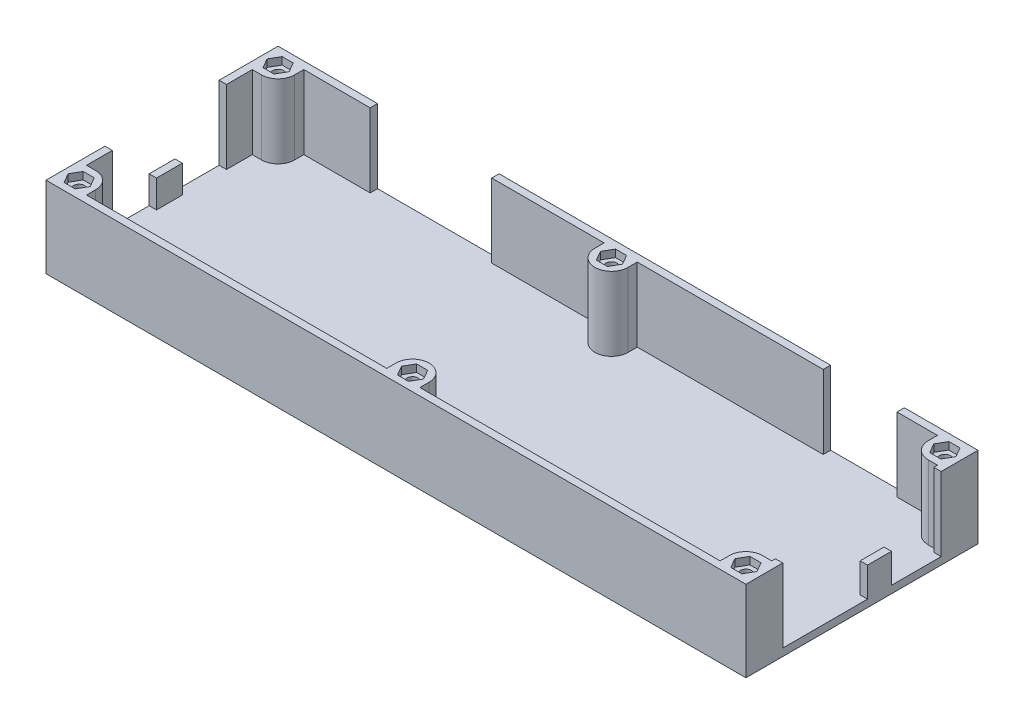
from build123d import *

# Parameters (mm, degrees)
BOSS_EXTRUDE1_DEPTH     = 2
SKETCH1_4_R             = 1.5
BOSS_EXTRUDE2_DEPTH     = 19
BOSS_EXTRUDE2_2_DEPTH   = 19
BOSS_EXTRUDE2_3_DEPTH   = 19
BOSS_EXTRUDE2_4_DEPTH   = 19
BOSS_EXTRUDE2_5_DEPTH   = 19
BOSS_EXTRUDE2_6_DEPTH   = 19
SKETCH1_5_R             = 1.5
BOSS_EXTRUDE3_DEPTH     = 20
BOSS_EXTRUDE4_DEPTH     = 22
SKETCH2_W               = 23
SKETCH2_H               = 8
SKETCH2_W_2             = 13.5
SKETCH2_H_2             = 13.3
CUT_EXTRUDE1_DEPTH      = 3
SKETCH3_W               = 20
SKETCH3_H               = 12
SKETCH3_W_2             = 33
CUT_EXTRUDE2_DEPTH      = 3
SKETCH4_W               = 12
SKETCH4_H               = 7.5
CUT_EXTRUDE3_DEPTH      = 3
CUT_EXTRUDE4_DEPTH      = 194.845943986
CUT_EXTRUDE4_DEPTH_BACK = 2
SKETCH6_W               = 20
SKETCH6_H               = 8
SKETCH6_W_2             = 33
CUT_EXTRUDE5_DEPTH      = 2
CUT_EXTRUDE6_DEPTH      = 194.845943986
CUT_EXTRUDE6_DEPTH_BACK = 2


with BuildPart() as part:
    # Sketch1 → Boss-Extrude1 (new body)
    with BuildSketch(Plane(origin=(0, 0, 0), x_dir=(1, 0, 0), z_dir=(0, 1, 0))):
        with BuildLine():
            Line((-90.5, 22.5), (-93, 22.5))
            Line((-93, 22.5), (-93, -22.5))
            Line((-93, -22.5), (-90.5, -22.5))
            ThreePointArc((-90.5, -22.5), (-87.318019485, -23.818019485), (-86, -27))
            Line((-86, -27), (-86, -29.5))
            Line((-86, -29.5), (-4.5, -29.5))
            Line((-4.5, -29.5), (-4.5, -27))
            ThreePointArc((-4.5, -27), (0, -22.5), (4.5, -27))
            Line((4.5, -27), (4.5, -29.5))
            Line((4.5, -29.5), (86, -29.5))
            Line((86, -29.5), (86, -27))
            ThreePointArc((86, -27), (87.318019485, -23.818019485), (90.5, -22.5))
            Line((90.5, -22.5), (93, -22.5))
            Line((93, -22.5), (93, 22.5))
            Line((93, 22.5), (90.5, 22.5))
            ThreePointArc((90.5, 22.5), (87.318019485, 23.818019485), (86, 27))
            Line((86, 27), (86, 29.5))
            Line((86, 29.5), (4.5, 29.5))
            Line((4.5, 29.5), (4.5, 27))
            ThreePointArc((4.5, 27), (0, 22.5), (-4.5, 27))
            Line((-4.5, 27), (-4.5, 29.5))
            Line((-4.5, 29.5), (-86, 29.5))
            Line((-86, 29.5), (-86, 27))
            ThreePointArc((-86, 27), (-87.318019485, 23.818019485), (-90.5, 22.5))
        make_face()
    extrude(amount=BOSS_EXTRUDE1_DEPTH)



with BuildPart() as body_2:
    # Sketch1_4 → Boss-Extrude2 (new body)
    with BuildSketch(Plane(origin=(0, 0, 0), x_dir=(1, 0, 0), z_dir=(0, 1, 0))):
        with Locations((-90.5, 27)):
            Circle(SKETCH1_4_R)
    extrude(amount=BOSS_EXTRUDE2_DEPTH)



with BuildPart() as body_3:
    # Sketch1_4 → Boss-Extrude2 2 (new body)
    with BuildSketch(Plane(origin=(0, 0, 0), x_dir=(1, 0, 0), z_dir=(0, 1, 0))):
        with Locations((90.5, 27)):
            Circle(SKETCH1_4_R)
    extrude(amount=BOSS_EXTRUDE2_2_DEPTH)


with BuildPart() as body_4:
    # Sketch1_4 → Boss-Extrude2 3 (new body)
    with BuildSketch(Plane(origin=(0, 0, 0), x_dir=(1, 0, 0), z_dir=(0, 1, 0))):
        with Locations((90.5, -27)):
            Circle(SKETCH1_4_R)
    extrude(amount=BOSS_EXTRUDE2_3_DEPTH)


with BuildPart() as body_5:
    # Sketch1_4 → Boss-Extrude2 4 (new body)
    with BuildSketch(Plane(origin=(0, 0, 0), x_dir=(1, 0, 0), z_dir=(0, 1, 0))):
        with Locations((-90.5, -27)):
            Circle(SKETCH1_4_R)
    extrude(amount=BOSS_EXTRUDE2_4_DEPTH)


with BuildPart() as body_6:
    # Sketch1_4 → Boss-Extrude2 5 (new body)
    with BuildSketch(Plane(origin=(0, 0, 0), x_dir=(1, 0, 0), z_dir=(0, 1, 0))):
        with Locations((0, 27)):
            Circle(SKETCH1_4_R)
    extrude(amount=BOSS_EXTRUDE2_5_DEPTH)


with BuildPart() as body_7:
    # Sketch1_4 → Boss-Extrude2 6 (new body)
    with BuildSketch(Plane(origin=(0, 0, 0), x_dir=(1, 0, 0), z_dir=(0, 1, 0))):
        with Locations((0, -27)):
            Circle(SKETCH1_4_R)
    extrude(amount=BOSS_EXTRUDE2_6_DEPTH)


with BuildPart() as body_2_1:
    add(body_2.part)

    add(body_3.part)  # Boss-Extrude3 merges body 3

    add(body_4.part)  # Boss-Extrude3 merges body 4

    add(body_5.part)  # Boss-Extrude3 merges body 5

    add(body_6.part)  # Boss-Extrude3 merges body 6

    add(body_7.part)  # Boss-Extrude3 merges body 7
    # Sketch1_5 → Boss-Extrude3 (add)
    # profile 1 of 6: a face of its own
    with BuildSketch(Plane(origin=(0, 0, 0), x_dir=(1, 0, 0), z_dir=(0, 1, 0))):
        Polygon((93.5, 27), (92, 29.598076211), (89, 29.598076211), (87.5, 27), (89, 24.401923789), (92, 24.401923789), align=None)
        with Locations((90.5, 27)):
            Circle(SKETCH1_5_R, mode=Mode.SUBTRACT)
    # profile 2 of 6: a face of its own
    with BuildSketch(Plane(origin=(0, 0, 0), x_dir=(1, 0, 0), z_dir=(0, 1, 0))):
        Polygon((-92, 29.598076211), (-93.5, 27), (-92, 24.401923789), (-89, 24.401923789), (-87.5, 27), (-89, 29.598076211), align=None)
        with Locations((-90.5, 27)):
            Circle(SKETCH1_5_R, mode=Mode.SUBTRACT)
    # profile 3 of 6: a face of its own
    with BuildSketch(Plane(origin=(0, 0, 0), x_dir=(1, 0, 0), z_dir=(0, 1, 0))):
        Polygon((87.5, -27), (89, -29.598076211), (92, -29.598076211), (93.5, -27), (92, -24.401923789), (89, -24.401923789), align=None)
        with Locations((90.5, -27)):
            Circle(SKETCH1_5_R, mode=Mode.SUBTRACT)
    # profile 4 of 6: a face of its own
    with BuildSketch(Plane(origin=(0, 0, 0), x_dir=(1, 0, 0), z_dir=(0, 1, 0))):
        Polygon((-93.5, -27), (-92, -29.598076211), (-89, -29.598076211), (-87.5, -27), (-89, -24.401923789), (-92, -24.401923789), align=None)
        with Locations((-90.5, -27)):
            Circle(SKETCH1_5_R, mode=Mode.SUBTRACT)
    # profile 5 of 6: a face of its own
    with BuildSketch(Plane(origin=(0, 0, 0), x_dir=(1, 0, 0), z_dir=(0, 1, 0))):
        Polygon((3, -27), (1.5, -24.401923789), (-1.5, -24.401923789), (-3, -27), (-1.5, -29.598076211), (1.5, -29.598076211), align=None)
        with Locations((0, -27)):
            Circle(SKETCH1_5_R, mode=Mode.SUBTRACT)
    # profile 6 of 6: a face of its own
    with BuildSketch(Plane(origin=(0, 0, 0), x_dir=(1, 0, 0), z_dir=(0, 1, 0))):
        Polygon((1.5, 24.401923789), (3, 27), (1.5, 29.598076211), (-1.5, 29.598076211), (-3, 27), (-1.5, 24.401923789), align=None)
        with Locations((0, 27)):
            Circle(SKETCH1_5_R, mode=Mode.SUBTRACT)
    extrude(amount=BOSS_EXTRUDE3_DEPTH)


with BuildPart() as part_1:
    add(part.part)

    add(body_2_1.part)  # Boss-Extrude4 merges body 2
    # Sketch1_6 → Boss-Extrude4 (add)
    with BuildSketch(Plane(origin=(0, 0, 0), x_dir=(1, 0, 0), z_dir=(0, 1, 0))):
        Polygon((-95, -22.5), (-95, -31.5), (-86, -31.5), (86, -31.5), (95, -31.5), (95, -22.5), (95, 22.5), (95, 31.5), (86, 31.5), (4.5, 31.5), (-4.5, 31.5), (-86, 31.5), (-95, 31.5), (-95, 22.5), align=None)
        Polygon((-89, -29.598076211), (-92, -29.598076211), (-93.5, -27), (-92, -24.401923789), (-89, -24.401923789), (-87.5, -27), align=None, mode=Mode.SUBTRACT)
        Polygon((-1.5, -24.401923789), (1.5, -24.401923789), (3, -27), (1.5, -29.598076211), (-1.5, -29.598076211), (-3, -27), align=None, mode=Mode.SUBTRACT)
        Polygon((92, -29.598076211), (89, -29.598076211), (87.5, -27), (89, -24.401923789), (92, -24.401923789), (93.5, -27), align=None, mode=Mode.SUBTRACT)
        Polygon((-92, 24.401923789), (-93.5, 27), (-92, 29.598076211), (-89, 29.598076211), (-87.5, 27), (-89, 24.401923789), align=None, mode=Mode.SUBTRACT)
        Polygon((1.5, 29.598076211), (3, 27), (1.5, 24.401923789), (-1.5, 24.401923789), (-3, 27), (-1.5, 29.598076211), align=None, mode=Mode.SUBTRACT)
        with BuildLine():
            Line((-93, -22.5), (-93, 22.5))
            Line((-93, 22.5), (-90.5, 22.5))
            ThreePointArc((-90.5, 22.5), (-87.318019485, 23.818019485), (-86, 27))
            Line((-86, 27), (-86, 29.5))
            Line((-86, 29.5), (-4.5, 29.5))
            Line((-4.5, 29.5), (-4.5, 27))
            ThreePointArc((-4.5, 27), (0, 22.5), (4.5, 27))
            Line((4.5, 27), (4.5, 29.5))
            Line((4.5, 29.5), (86, 29.5))
            Line((86, 29.5), (86, 27))
            ThreePointArc((86, 27), (87.318019485, 23.818019485), (90.5, 22.5))
            Line((90.5, 22.5), (93, 22.5))
            Line((93, 22.5), (93, -22.5))
            Line((93, -22.5), (90.5, -22.5))
            ThreePointArc((90.5, -22.5), (87.318019485, -23.818019485), (86, -27))
            Line((86, -27), (86, -29.5))
            Line((86, -29.5), (4.5, -29.5))
            Line((4.5, -29.5), (4.5, -27))
            ThreePointArc((4.5, -27), (0, -22.5), (-4.5, -27))
            Line((-4.5, -27), (-4.5, -29.5))
            Line((-4.5, -29.5), (-86, -29.5))
            Line((-86, -29.5), (-86, -27))
            ThreePointArc((-86, -27), (-87.318019485, -23.818019485), (-90.5, -22.5))
            Line((-90.5, -22.5), (-93, -22.5))
        make_face(mode=Mode.SUBTRACT)
        Polygon((89, 29.598076211), (92, 29.598076211), (93.5, 27), (92, 24.401923789), (89, 24.401923789), (87.5, 27), align=None, mode=Mode.SUBTRACT)
    extrude(amount=BOSS_EXTRUDE4_DEPTH)

    # Sketch2 → Cut-Extrude1 (cut)
    with BuildSketch(Plane(origin=(95, 0, 0), x_dir=(0, 0, -1), z_dir=(1, 0, 0))):
        with Locations((-10, 6)):
            Rectangle(SKETCH2_W, SKETCH2_H)
        with Locations((14.75, 8.65)):
            Rectangle(SKETCH2_W_2, SKETCH2_H_2)
    extrude(amount=-CUT_EXTRUDE1_DEPTH, mode=Mode.SUBTRACT)

    # Sketch3 → Cut-Extrude2 (cut)
    with BuildSketch(Plane(origin=(0, 0, -31.5), x_dir=(-1, 0, 0), z_dir=(0, 0, -1))):
        with Locations((-65, 8)):
            Rectangle(SKETCH3_W, SKETCH3_H)
        with Locations((51.5, 8)):
            Rectangle(SKETCH3_W_2, SKETCH3_H)
    extrude(amount=-CUT_EXTRUDE2_DEPTH, mode=Mode.SUBTRACT)

    # Sketch4 → Cut-Extrude3 (cut)
    with BuildSketch(Plane.ZY.offset(95)):
        with Locations((-9.5, 5.75)):
            Rectangle(SKETCH4_W, SKETCH4_H)
        with Locations((9.5, 5.75)):
            Rectangle(SKETCH4_W, SKETCH4_H)
    extrude(amount=-CUT_EXTRUDE3_DEPTH, mode=Mode.SUBTRACT)

    # Sketch5 → Cut-Extrude4 (cut, two sides: drawn at the far end of the back side and taken through both)
    with BuildSketch(Plane(origin=(95, 0, 0), x_dir=(0, 0, -1), z_dir=(1, 0, 0)).offset(-CUT_EXTRUDE4_DEPTH_BACK)):
        Polygon((21.5, 146.769333883), (21.5, 22), (21.5, 15.3), (8, 15.3), (8, 10), (-21.5, 10), (-21.5, 22), (-21.5, 146.769333883), (-21.5, 396.30800165), (21.5, 396.30800165), align=None)
    extrude(amount=CUT_EXTRUDE4_DEPTH + CUT_EXTRUDE4_DEPTH_BACK, mode=Mode.SUBTRACT)

    # Sketch6 → Cut-Extrude5 (cut)
    with BuildSketch(Plane(origin=(0, 0, -31.5), x_dir=(-1, 0, 0), z_dir=(0, 0, -1))):
        with Locations((-65, 18)):
            Rectangle(SKETCH6_W, SKETCH6_H)
        with Locations((51.5, 18)):
            Rectangle(SKETCH6_W_2, SKETCH6_H)
    extrude(amount=-CUT_EXTRUDE5_DEPTH, mode=Mode.SUBTRACT)

    # Sketch7 → Cut-Extrude6 (cut, two sides: drawn at the far end of the back side and taken through both)
    with BuildSketch(Plane.ZY.offset(95).offset(-CUT_EXTRUDE6_DEPTH_BACK)):
        Polygon((15.5, 135.788245963), (15.5, 22), (15.5, 9.5), (-15.5, 9.5), (-15.5, 22), (-15.5, 135.788245963), (-15.5, 363.364737888), (15.5, 363.364737888), align=None)
    extrude(amount=CUT_EXTRUDE6_DEPTH + CUT_EXTRUDE6_DEPTH_BACK, mode=Mode.SUBTRACT)


solid = part_1.part
